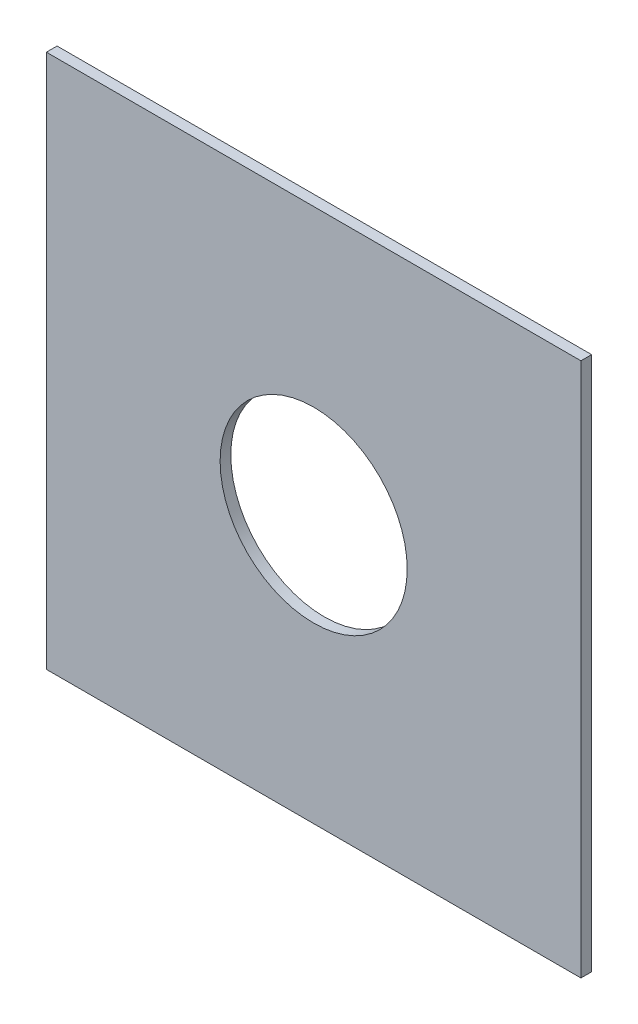
from build123d import *

# Parameters (mm, degrees)
SKETCH1_W           = 100
SKETCH1_H           = 100
SKETCH1_R           = 17.5
BOSS_EXTRUDE1_DEPTH = 2


with BuildPart() as part:
    # Sketch1 → Boss-Extrude1 (new body)
    with BuildSketch(Plane.XY):
        with Locations((-259.301545348, -148.573704322)):
            Rectangle(SKETCH1_W, SKETCH1_H)
        with Locations((-259.301545348, -148.573704322)):
            Circle(SKETCH1_R, mode=Mode.SUBTRACT)
    extrude(amount=BOSS_EXTRUDE1_DEPTH)


solid = part.part
